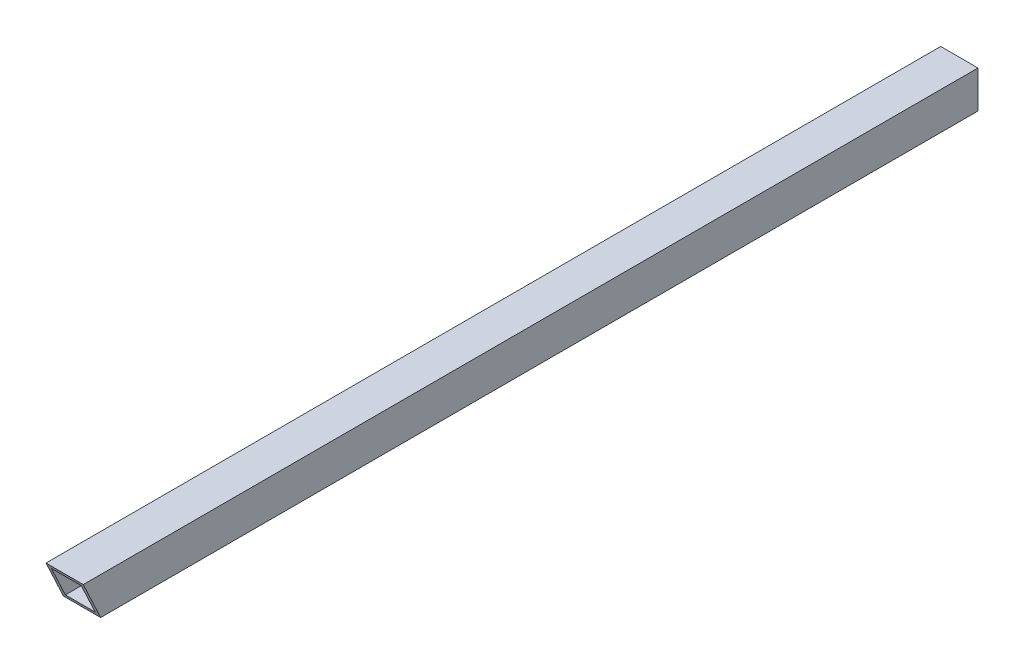
from build123d import *

# Parameters (mm, degrees)
SKETCH4_W           = 19.05
SKETCH4_H           = 19.05
SKETCH4_W_2         = 15.24
SKETCH4_H_2         = 15.24
BOSS_EXTRUDE2_DEPTH = 457.2
CUT_EXTRUDE1_DEPTH  = 20.05


with BuildPart() as part:
    # Sketch4 → Boss-Extrude2 (new body)
    with BuildSketch(Plane.XY):
        Rectangle(SKETCH4_W, SKETCH4_H)
        Rectangle(SKETCH4_W_2, SKETCH4_H_2, mode=Mode.SUBTRACT)
    extrude(amount=BOSS_EXTRUDE2_DEPTH)

    # Sketch5 → Cut-Extrude1 (cut, through all)
    with BuildSketch(Plane(origin=(9.525, 0, 0), x_dir=(0, 0, -1), z_dir=(1, 0, 0))):
        Polygon((-457.2, 9.525), (-448.316839112, -9.525), (-457.2, -9.525), align=None)
    extrude(amount=-CUT_EXTRUDE1_DEPTH, mode=Mode.SUBTRACT)


solid = part.part
